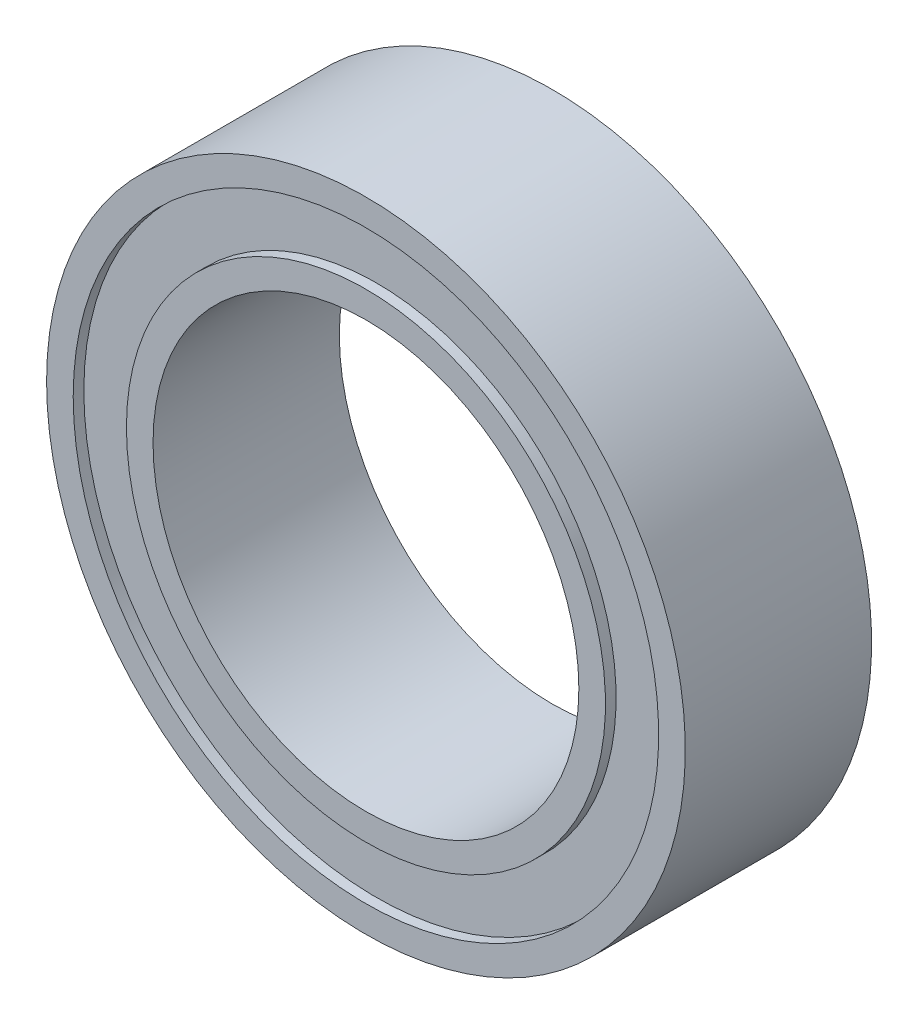
from build123d import *


with BuildPart() as part:
    # Sketch1 → Revolve1 (revolve)
    with BuildSketch(Plane(origin=(0, 0, 0), x_dir=(1, 0, 0), z_dir=(0, 1, 0))):
        Polygon((5.5, 1.75), (6, 1.75), (6, -1.75), (5.5, -1.75), (5.5, -1.55), (4.5, -1.55), (4.5, -1.75), (4, -1.75), (4, 1.75), (4.5, 1.75), (4.5, 1.55), (5.5, 1.55), align=None)
    revolve(axis=Axis((0, 0, -1.75), (0, 0, 1)))


solid = part.part
